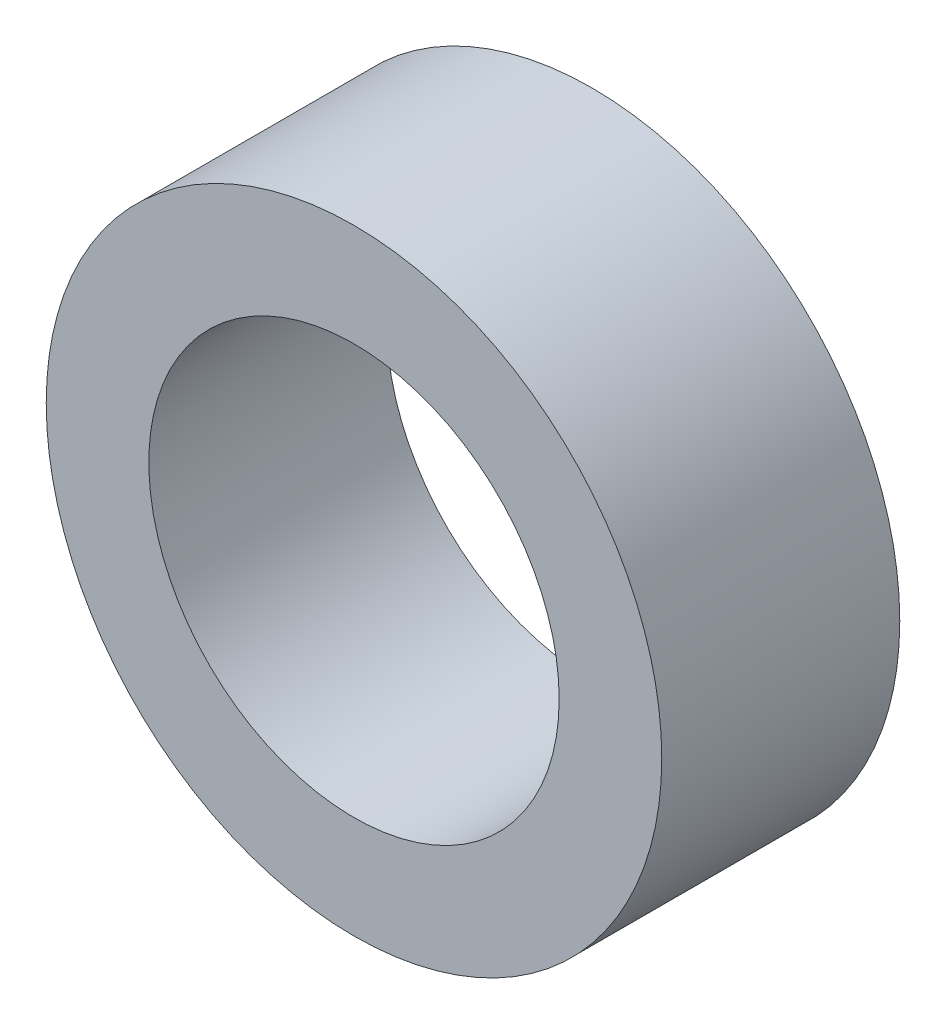
from build123d import *

# Parameters (mm, degrees)
SKETCH1_R           = 9.525
SKETCH1_R_2         = 6.35
BOSS_EXTRUDE1_DEPTH = 7.366


with BuildPart() as part:
    # Sketch1 → Boss-Extrude1 (new body)
    with BuildSketch(Plane.XY):
        Circle(SKETCH1_R)
        Circle(SKETCH1_R_2, mode=Mode.SUBTRACT)
    extrude(amount=BOSS_EXTRUDE1_DEPTH)


solid = part.part
